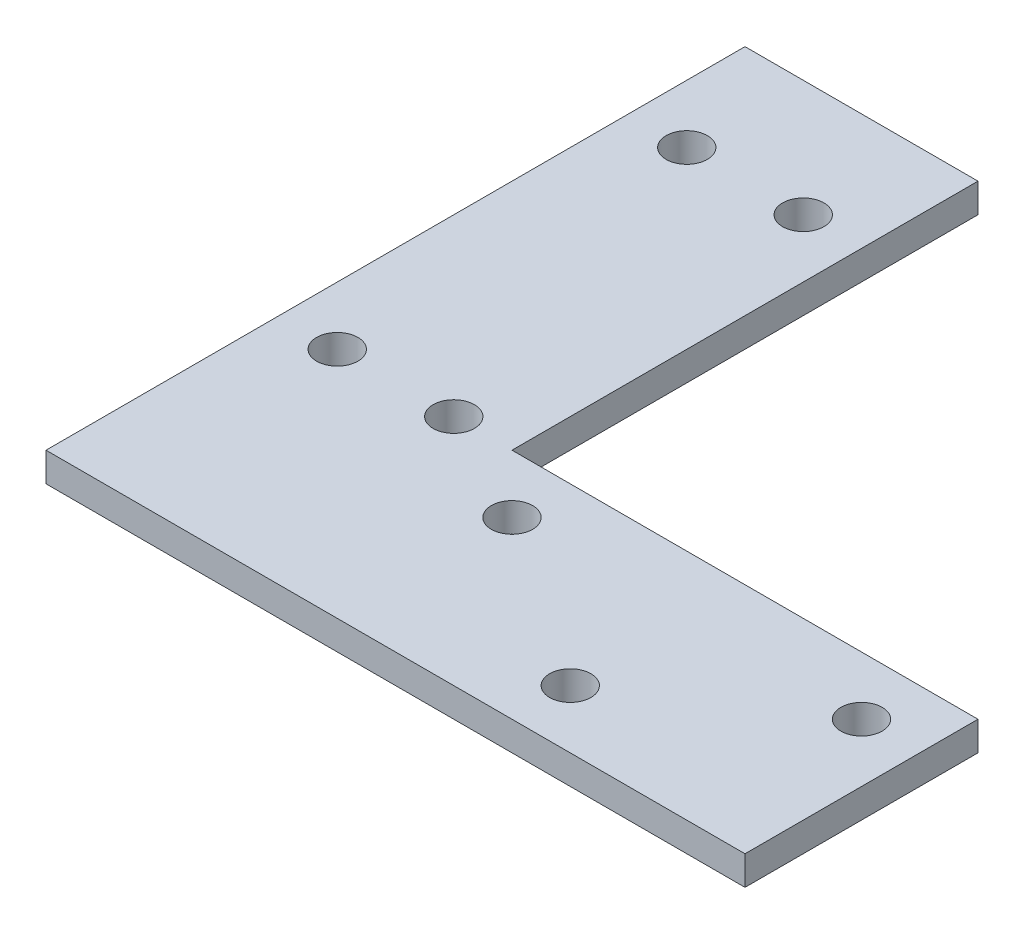
from build123d import *

# Parameters (mm, degrees)
SKETCH1_R           = 2.25
BOSS_EXTRUDE1_DEPTH = 3.175


with BuildPart() as part:
    # Sketch1 → Boss-Extrude1 (new body)
    with BuildSketch(Plane(origin=(0, 0, 0), x_dir=(1, 0, 0), z_dir=(0, 1, 0))):
        Polygon((0, 0), (76.2, 0), (76.2, 25.4), (25.4, 25.4), (25.4, 76.2), (0, 76.2), align=None)
        with Locations((31.75, 19.05)):
            Circle(SKETCH1_R, mode=Mode.SUBTRACT)
        with Locations((69.85, 19.05)):
            Circle(SKETCH1_R, mode=Mode.SUBTRACT)
        with Locations((50.8, 6.35)):
            Circle(SKETCH1_R, mode=Mode.SUBTRACT)
        with Locations((19.05, 63.5)):
            Circle(SKETCH1_R, mode=Mode.SUBTRACT)
        with Locations((19.05, 25.4)):
            Circle(SKETCH1_R, mode=Mode.SUBTRACT)
        with Locations((6.35, 25.4)):
            Circle(SKETCH1_R, mode=Mode.SUBTRACT)
        with Locations((6.35, 63.5)):
            Circle(SKETCH1_R, mode=Mode.SUBTRACT)
    extrude(amount=BOSS_EXTRUDE1_DEPTH)


solid = part.part
